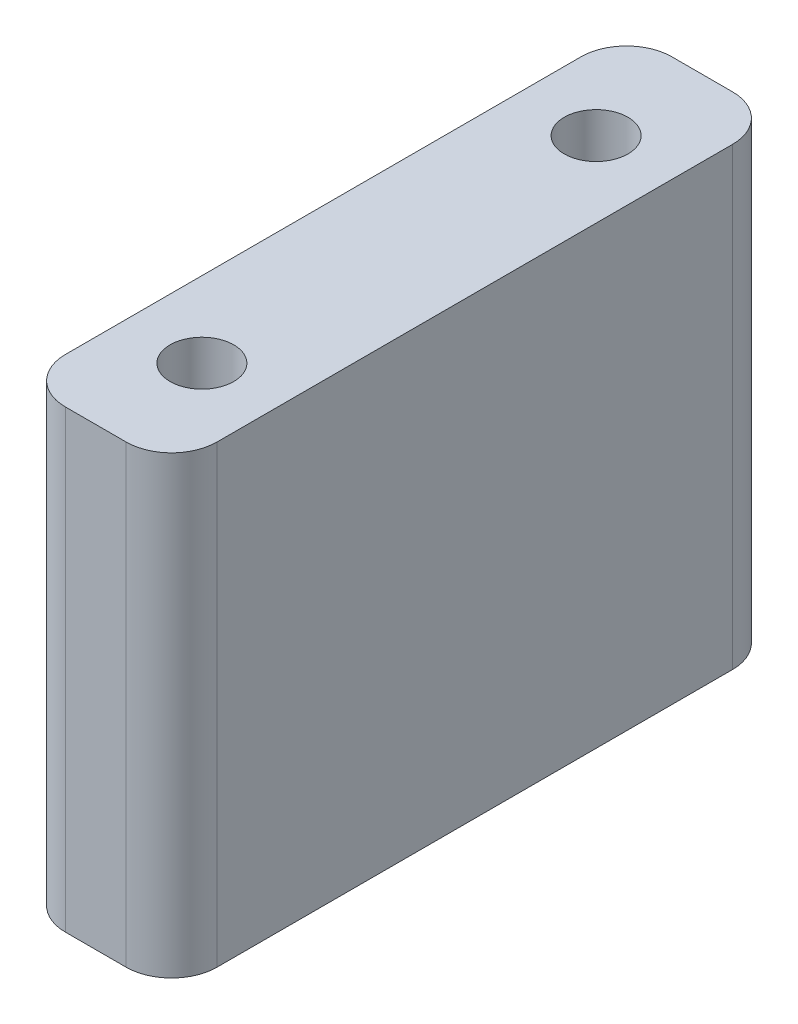
from build123d import *

# Parameters (mm, degrees)
SKETCH_1_W      = 10
SKETCH_1_H      = 40
SKETCH_1_R      = 2.1
EXTRUDE_1_DEPTH = 30
FILLET_1_R      = 3


with BuildPart() as part:
    # 草图1 → 凸台-拉伸1 (new body)
    with BuildSketch(Plane(origin=(0, 0, 0), x_dir=(1, 0, 0), z_dir=(0, 1, 0))):
        with Locations((-5, -20)):
            Rectangle(SKETCH_1_W, SKETCH_1_H)
        with Locations((-5, -7)):
            Circle(SKETCH_1_R, mode=Mode.SUBTRACT)
        with Locations((-5, -33)):
            Circle(SKETCH_1_R, mode=Mode.SUBTRACT)
    extrude(amount=EXTRUDE_1_DEPTH)

    # 圆角1
    fillet_1_edges = [part.edges().sort_by_distance(p)[0] for p in [
        (-10, 15, 0),
        (0, 15, 0),
        (0, 15, 40),
        (-10, 15, 40),
    ]]
    fillet(fillet_1_edges, radius=FILLET_1_R)


solid = part.part
